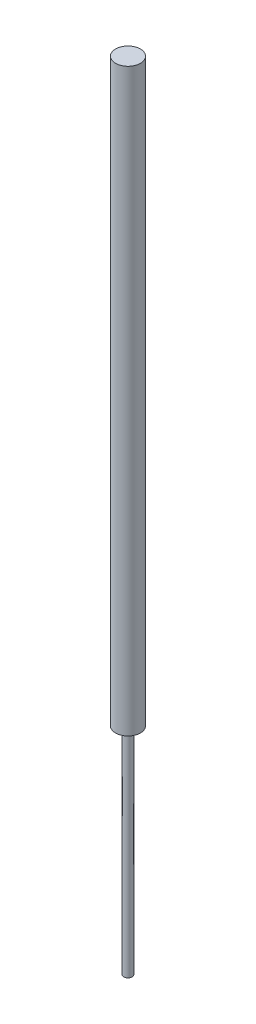
from build123d import *


with BuildPart() as part:
    # Sketch1 → Revolve1 (revolve)
    with BuildSketch(Plane.XY):
        Polygon((0, 0), (1.5875, 0), (1.5875, 82.55), (4.7625, 82.55), (4.7625, 304.8), (0, 304.8), align=None)
    revolve(axis=Axis((0, 304.8, 0), (0, -1, 0)))


solid = part.part
